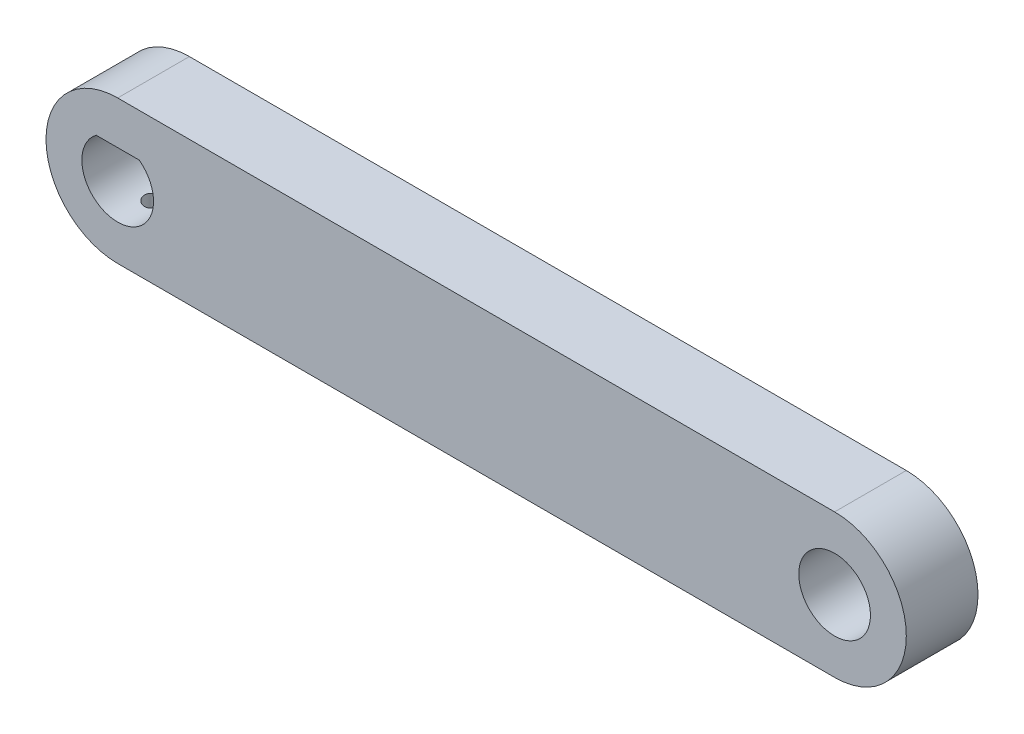
from build123d import *

# Parameters (mm, degrees)
SKETCH_1_R          = 5
EXTRUDE_1_DEPTH     = 10
SKETCH_2_R          = 1.25
CUT_EXTRUDE_1_DEPTH = 10


with BuildPart() as part:
    # 草图1 → 凸台-拉伸1 (new body)
    with BuildSketch(Plane.XY):
        with BuildLine():
            Line((-50, 10), (50, 10))
            ThreePointArc((50, 10), (60, 0), (50, -10))
            Line((50, -10), (-50, -10))
            ThreePointArc((-50, -10), (-60, 0), (-50, 10))
        make_face()
        with Locations((50, 0)):
            Circle(SKETCH_1_R, mode=Mode.SUBTRACT)
        with BuildLine():
            Line((-53, 4), (-47, 4))
            ThreePointArc((-47, 4), (-50, -5), (-53, 4))
        make_face(mode=Mode.SUBTRACT)
    extrude(amount=EXTRUDE_1_DEPTH)

    # 草图2 → 切除-拉伸1 (cut)
    with BuildSketch(Plane.XZ.offset(10)):
        with Locations((-50, 5)):
            Circle(SKETCH_2_R)
    extrude(amount=-CUT_EXTRUDE_1_DEPTH, mode=Mode.SUBTRACT)


solid = part.part
